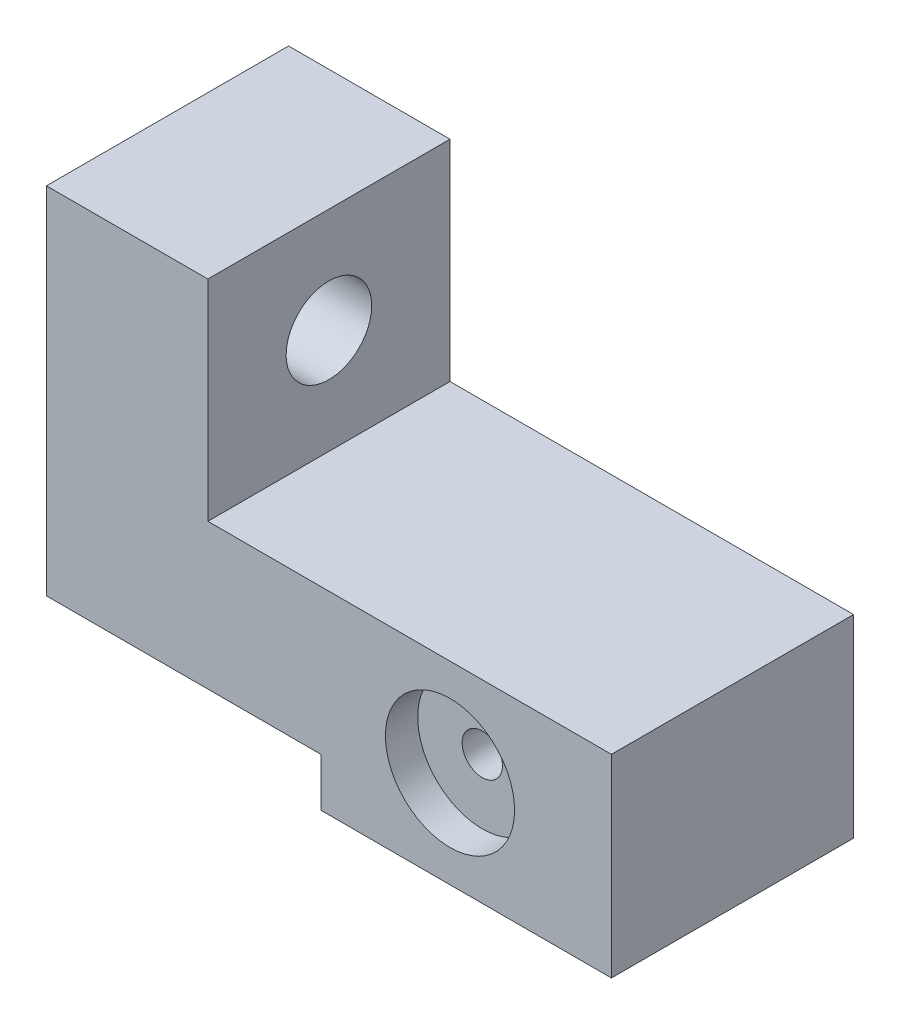
from build123d import *

# Parameters (mm, degrees)
BOSS_EXTRUDE1_DEPTH = 15
SKETCH3_R           = 2.65
CUT_EXTRUDE1_DEPTH  = 15
M3_TAPPED_HOLE1_D   = 2.5
SKETCH7_R           = 4
CUT_EXTRUDE2_DEPTH  = 2


with BuildPart() as part:
    # Sketch1 → Boss-Extrude1 (new body)
    with BuildSketch(Plane.XY):
        Polygon((35, 0), (17, 0), (17, 3), (0, 3), (0, 25), (10, 25), (10, 12), (35, 12), align=None)
    extrude(amount=BOSS_EXTRUDE1_DEPTH)

    # Sketch3 → Cut-Extrude1 (cut)
    with BuildSketch(Plane(origin=(10, 0, 0), x_dir=(0, 0, -1), z_dir=(1, 0, 0))):
        with Locations((-7.5, 18.5)):
            Circle(SKETCH3_R)
    extrude(amount=-CUT_EXTRUDE1_DEPTH, mode=Mode.SUBTRACT)

    # M3 Tapped Hole1 (through all)
    with Locations(Plane(origin=(25, 6, 15), x_dir=(1, 0, 0), z_dir=(0, 0, 1))):
        with Locations((0, 0)):
            Hole(M3_TAPPED_HOLE1_D / 2)

    # Sketch7 → Cut-Extrude2 (cut)
    with BuildSketch(Plane.XY.offset(15)):
        with Locations((25, 6)):
            Circle(SKETCH7_R)
    extrude(amount=-CUT_EXTRUDE2_DEPTH, mode=Mode.SUBTRACT)


solid = part.part
